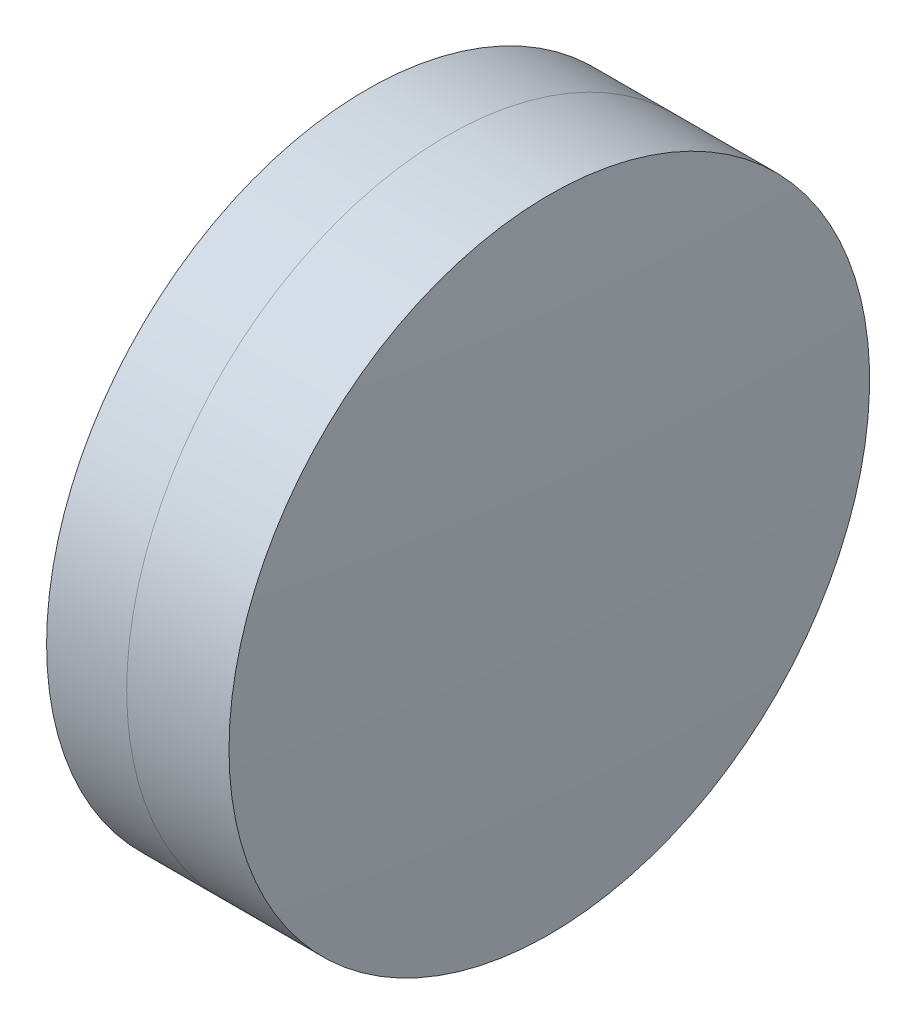
from build123d import *


with BuildPart() as part:
    # 草图1 one side → 旋转1 (revolve)
    with BuildSketch(Plane(origin=(0, 0, 0), x_dir=(1, 0, 0), z_dir=(0, 1, 0)), mode=Mode.PRIVATE) as revolve_1_sk:
        with BuildLine():
            ThreePointArc((33.614954095, 8), (33.226077472, 4.00839845), (33.096270616, 0))
            Line((33.096270616, 0), (36.416270616, 0))
            ThreePointArc((36.416270616, 0), (36.215829053, 4.019939197), (35.616492776, 8))
            Line((35.616492776, 8), (33.614954095, 8))
        make_face()
    revolve(revolve_1_sk.sketch.rotate(Axis((-9.702612178, 0, 0), (1, 0, 0)), 180), axis=Axis((-9.702612178, 0, 0), (1, 0, 0)))  # turned: the seam where the file's is


with BuildPart() as body_2:
    # 草图2 one side → 旋转3 (revolve)
    with BuildSketch(Plane(origin=(0, 0, 0), x_dir=(1, 0, 0), z_dir=(0, 1, 0)), mode=Mode.PRIVATE) as revolve_3_sk:
        with BuildLine():
            Line((38.17090631, 8), (35.616492776, 8))
            ThreePointArc((35.616492776, 8), (36.215829053, 4.019939197), (36.416270616, 0))
            Line((36.416270616, 0), (38.416270616, 0))
            ThreePointArc((38.416270616, 0), (38.354915121, 4.001880922), (38.17090631, 8))
        make_face()
    revolve(revolve_3_sk.sketch.rotate(Axis((-0.551919993, 0, 0), (1, 0, 0)), 180), axis=Axis((-0.551919993, 0, 0), (1, 0, 0)))  # turned: the seam where the file's is


solid = Compound([part.part, body_2.part])
